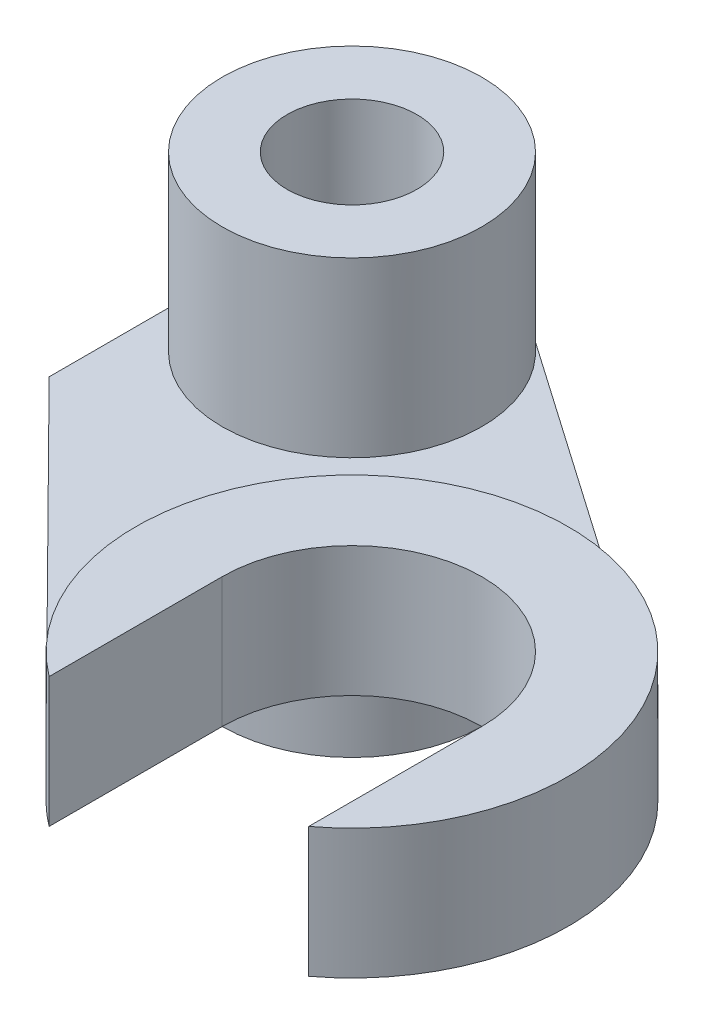
from build123d import *

# Parameters (mm, degrees)
SKETCH1_R                = 15
BOSS_EXTRUDE1_DEPTH      = 10
BOSS_EXTRUDE2_DEPTH      = 50
BOSS_EXTRUDE2_DEPTH_BACK = 50
SKETCH1_3_R              = 15
BOSS_EXTRUDE3_DEPTH      = 30


with BuildPart() as part:
    # Sketch1 → Boss-Extrude1 (new body)
    with BuildSketch(Plane(origin=(0, 0, 0), x_dir=(1, 0, 0), z_dir=(0, 1, 0))):
        with BuildLine():
            Line((108.548527268, -38.951472732), (17.129116361, 24.629116361))
            ThreePointArc((17.129116361, 24.629116361), (-13.894720385, 26.588282107), (-30, 0))
            Line((-30, 0), (-30, -40))
            Line((-30, -40), (44.477364607, -115.187247331))
            ThreePointArc((44.477364607, -115.187247331), (47.1504249, -117.694899068), (50, -120))
            Line((50, -120), (50, -80))
            ThreePointArc((50, -80), (80, -50), (110, -80))
            Line((110, -80), (110, -120))
            ThreePointArc((110, -120), (129.991983901, -79.104709192), (108.548527268, -38.951472732))
        make_face()
        Circle(SKETCH1_R, mode=Mode.SUBTRACT)
    extrude(amount=BOSS_EXTRUDE1_DEPTH)

    # Sketch1_3 → Boss-Extrude2 (add, two sides: drawn at the far end of the back side and taken through both)
    with BuildSketch(Plane(origin=(0, 0, 0), x_dir=(1, 0, 0), z_dir=(0, 1, 0)).offset(-BOSS_EXTRUDE2_DEPTH_BACK)):
        with BuildLine():
            ThreePointArc((17.129116361, 24.629116361), (-13.894720385, 26.588282107), (-30, 0))
            ThreePointArc((-30, 0), (0, -30), (30, 0))
            ThreePointArc((30, 0), (26.588282107, 13.894720385), (17.129116361, 24.629116361))
        make_face()
        Circle(SKETCH1_3_R, mode=Mode.SUBTRACT)
    extrude(amount=BOSS_EXTRUDE2_DEPTH + BOSS_EXTRUDE2_DEPTH_BACK)

    # Sketch1_4 → Boss-Extrude3 (add)
    with BuildSketch(Plane(origin=(0, 0, 0), x_dir=(1, 0, 0), z_dir=(0, 1, 0))):
        with BuildLine():
            ThreePointArc((108.548527268, -38.951472732), (41.7229458, -47.830649341), (44.477364607, -115.187247331))
            ThreePointArc((44.477364607, -115.187247331), (47.1504249, -117.694899068), (50, -120))
            Line((50, -120), (50, -80))
            ThreePointArc((50, -80), (80, -50), (110, -80))
            Line((110, -80), (110, -120))
            ThreePointArc((110, -120), (129.991983901, -79.104709192), (108.548527268, -38.951472732))
        make_face()
    extrude(amount=BOSS_EXTRUDE3_DEPTH)


solid = part.part
